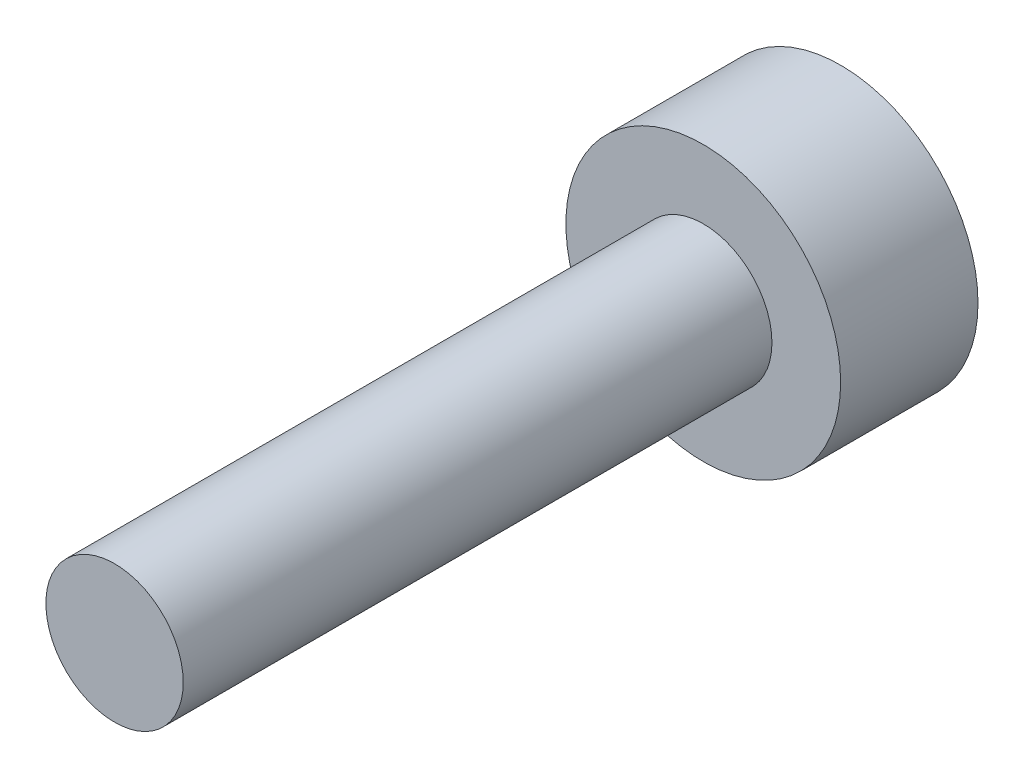
from build123d import *

# Parameters (mm, degrees)
SKETCH_1_R          = 1.4
EXTRUDE_1_DEPTH     = 1.4
SKETCH_2_R          = 0.7
EXTRUDE_2_DEPTH     = 10
CUT_EXTRUDE_1_DEPTH = 1
SKETCH_4_R          = 2.875018911
CUT_EXTRUDE_2_DEPTH = 4


with BuildPart() as part:
    # 草图1 → 凸台-拉伸1 (new body)
    with BuildSketch(Plane.XY):
        Circle(SKETCH_1_R)
    extrude(amount=EXTRUDE_1_DEPTH)

    # 草图2 → 凸台-拉伸2 (add)
    with BuildSketch(Plane.XY.offset(1.4)):
        Circle(SKETCH_2_R)
    extrude(amount=EXTRUDE_2_DEPTH)

    # 草图3 → 切除-拉伸1 (cut)
    with BuildSketch(Plane(origin=(0, 0, 0), x_dir=(-1, 0, 0), z_dir=(0, 0, -1))):
        Polygon((0, 0.68), (-0.588897275, 0.34), (-0.588897275, -0.34), (0, -0.68), (0.588897275, -0.34), (0.588897275, 0.34), align=None)
    extrude(amount=-CUT_EXTRUDE_1_DEPTH, mode=Mode.SUBTRACT)

    # 草图4 → 切除-拉伸2 (cut)
    with BuildSketch(Plane.XY.offset(11.4)):
        Circle(SKETCH_4_R)
    extrude(amount=-CUT_EXTRUDE_2_DEPTH, mode=Mode.SUBTRACT)


solid = part.part
